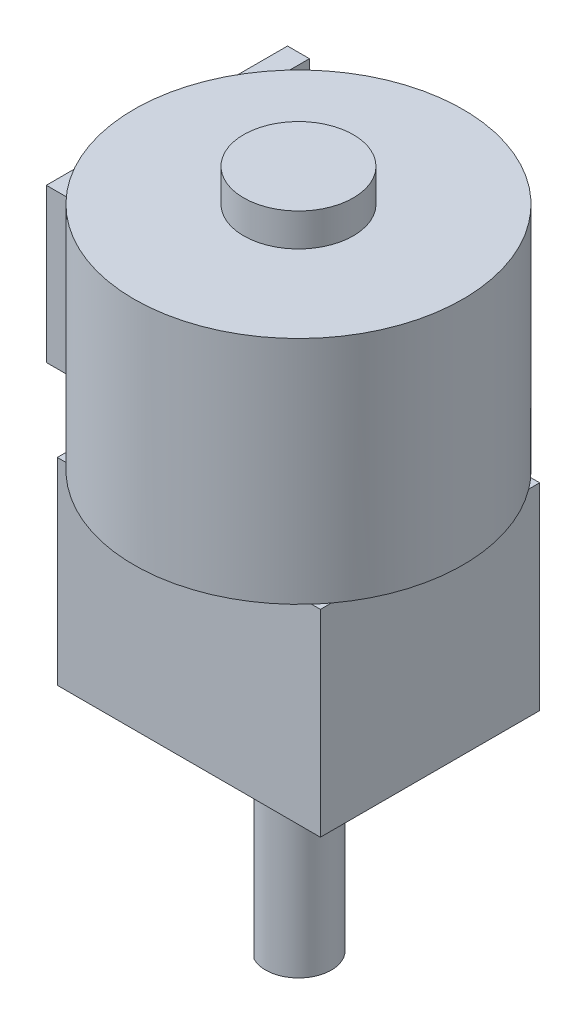
from build123d import *

# Parameters (mm, degrees)
SKETCH1_W                  = 12
SKETCH1_H                  = 10
BOSS_EXTRUDE1_DEPTH        = 9
SKETCH2_R                  = 2
BOSS_EXTRUDE2_DEPTH        = 1
BOSS_EXTRUDE3_DEPTH        = 9
M1_6_CLEARANCE_HOLE1_D     = 1.8
M1_6_CLEARANCE_HOLE1_DEPTH = 2
M1_6_CLEARANCE_HOLE1_TIP   = 0.540774557
SKETCH6_R                  = 7.5
BOSS_EXTRUDE4_DEPTH        = 10.5
SKETCH7_R                  = 2.5
BOSS_EXTRUDE5_DEPTH        = 1.5
SKETCH8_W                  = 1
SKETCH8_H                  = 11
BOSS_EXTRUDE6_DEPTH        = 3.5


with BuildPart() as part:
    # Sketch1 → Boss-Extrude1 (new body)
    with BuildSketch(Plane(origin=(0, 0, 0), x_dir=(1, 0, 0), z_dir=(0, 1, 0))):
        Rectangle(SKETCH1_W, SKETCH1_H)
    extrude(amount=BOSS_EXTRUDE1_DEPTH)

    # Sketch2 → Boss-Extrude2 (add)
    with BuildSketch(Plane.XZ):
        Circle(SKETCH2_R)
    extrude(amount=BOSS_EXTRUDE2_DEPTH)

    # Sketch3 → Boss-Extrude3 (add)
    with BuildSketch(Plane(origin=(0, -1, 0), x_dir=(-1, 0, 0), z_dir=(0, -1, 0))):
        with BuildLine():
            Line((0.7, 1.326649916), (0.7, -1.326649916))
            ThreePointArc((0.7, -1.326649916), (-1.5, 0), (0.7, 1.326649916))
        make_face()
    extrude(amount=BOSS_EXTRUDE3_DEPTH)

    # M1.6 Clearance Hole1
    with Locations(Plane(origin=(0, 0, 0), x_dir=(-1, 0, 0), z_dir=(0, -1, 0))):
        with Locations((4.5, 0), (-4.5, 0)):
            Hole(M1_6_CLEARANCE_HOLE1_D / 2, depth=M1_6_CLEARANCE_HOLE1_DEPTH)
            with Locations((0, 0, -(M1_6_CLEARANCE_HOLE1_DEPTH + M1_6_CLEARANCE_HOLE1_TIP / 2))):  # 118° drill point
                Cone(0, M1_6_CLEARANCE_HOLE1_D / 2, M1_6_CLEARANCE_HOLE1_TIP, mode=Mode.SUBTRACT)

    # Sketch6 → Boss-Extrude4 (add)
    with BuildSketch(Plane(origin=(0, 9, 0), x_dir=(1, 0, 0), z_dir=(0, 1, 0))):
        Circle(SKETCH6_R)
    extrude(amount=BOSS_EXTRUDE4_DEPTH)

    # Sketch7 → Boss-Extrude5 (add)
    with BuildSketch(Plane(origin=(0, 19.5, 0), x_dir=(1, 0, 0), z_dir=(0, 1, 0))):
        Circle(SKETCH7_R)
    extrude(amount=BOSS_EXTRUDE5_DEPTH)


with BuildPart() as body_2:
    # Sketch8 → Boss-Extrude6 (new body, symmetric)
    with BuildSketch(Plane(origin=(0, 14, 0), x_dir=(1, 0, 0), z_dir=(0, 1, 0))):
        with Locations((-8, 2.5)):
            Rectangle(SKETCH8_W, SKETCH8_H)
    extrude(amount=BOSS_EXTRUDE6_DEPTH, both=True)


solid = Compound([part.part, body_2.part])
